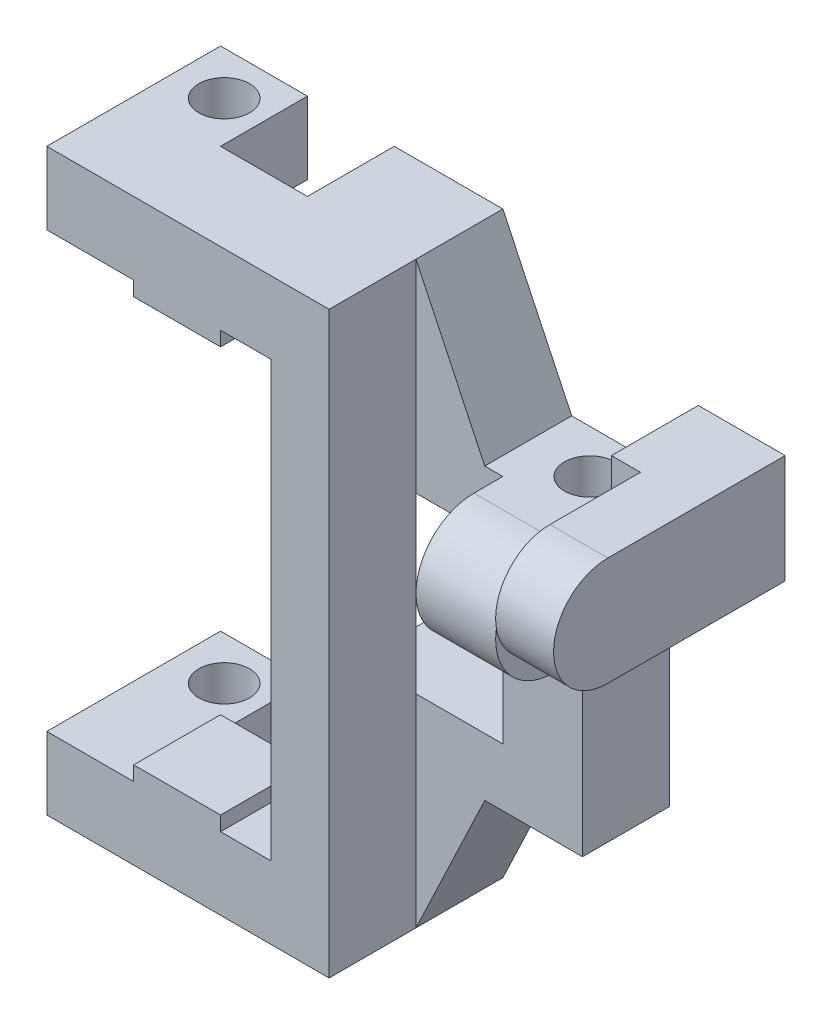
from build123d import *

# Parameters (mm, degrees)
BOSS_EXTRUDE1_DEPTH  = 6
SKETCH2_R            = 1.75
CUT_EXTRUDE1_DEPTH   = 41
SKETCH3_R            = 1.5
BOSS_EXTRUDE7_DEPTH  = 5.5
SKETCH4_W            = 4
SKETCH4_H            = 12
BOSS_EXTRUDE8_DEPTH  = 6
SKETCH7_W            = 6
SKETCH7_H            = 6
CUT_EXTRUDE2_DEPTH   = 40
BOSS_EXTRUDE9_DEPTH  = 6
BOSS_EXTRUDE10_DEPTH = 10
CUT_EXTRUDE3_REACH   = 41
SKETCH12_W           = 6
SKETCH12_H           = 6
BOSS_EXTRUDE11_DEPTH = 1
SKETCH13_W           = 6
SKETCH13_H           = 6
BOSS_EXTRUDE12_DEPTH = 1


with BuildPart() as part:
    # Sketch1 → Boss-Extrude1 (new body)
    with BuildSketch(Plane.XY):
        Polygon((6, 4), (-4, 4), (-4, -5), (-19.5, -5), (-19.5, -10), (0, -10), (4.75, 0), (11.5, 0), (11.5, 20), (4.75, 20), (0, 30), (-19.5, 30), (-19.5, 25), (-4, 25), (-4, 16), (6, 16), align=None)
    extrude(amount=BOSS_EXTRUDE1_DEPTH)

    # Sketch2 → Cut-Extrude1 (cut, through all)
    with BuildSketch(Plane.XZ.offset(10)):
        with Locations((9, 3)):
            Circle(SKETCH2_R)
        with Locations((-16.25, 3)):
            Circle(SKETCH2_R)
    extrude(amount=-CUT_EXTRUDE1_DEPTH, mode=Mode.SUBTRACT)

    # Sketch3 → Boss-Extrude7 (add)
    with BuildSketch(Plane(origin=(11.5, 0, 0), x_dir=(0, 0, -1), z_dir=(1, 0, 0))):
        with BuildLine():
            Line((-8, 12), (-6, 12))
            Line((-6, 12), (-6, 20))
            Line((-6, 20), (-8, 20))
            ThreePointArc((-8, 20), (-12, 16), (-8, 12))
        make_face()
        with Locations((-8, 16)):
            Circle(SKETCH3_R, mode=Mode.SUBTRACT)
    extrude(amount=-BOSS_EXTRUDE7_DEPTH)

    # Sketch4 → Boss-Extrude8 (add)
    with BuildSketch(Plane.XY.offset(6)):
        with Locations((-2, 10)):
            Rectangle(SKETCH4_W, SKETCH4_H)
        Polygon((-4, 16), (-4, 25), (-19.5, 25), (-19.5, 30), (0, 30), (0, 24), (0, 16), align=None)
        Polygon((-19.5, -5), (-19.5, -10), (0, -10), (0, 4), (-4, 4), (-4, -5), align=None)
    extrude(amount=BOSS_EXTRUDE8_DEPTH)

    # Sketch7 → Cut-Extrude2 (cut)
    with BuildSketch(Plane.XZ.offset(10)):
        with Locations((-10.5, 3)):
            Rectangle(SKETCH7_W, SKETCH7_H)
    extrude(amount=-CUT_EXTRUDE2_DEPTH, mode=Mode.SUBTRACT)

    # Sketch9 → Boss-Extrude9 (add)
    with BuildSketch(Plane(origin=(0, 0, 0), x_dir=(-1, 0, 0), z_dir=(0, 0, -1))):
        Polygon((-17.5, 17.5), (-11.5, 12), (-11.5, 20), (-13.5, 20), (-13.5, 25), (-19.5, 25), (-19.5, 20), (-19.5, 17.5), align=None)
    extrude(amount=-BOSS_EXTRUDE9_DEPTH)

    # Sketch10 → Boss-Extrude10 (add)
    with BuildSketch(Plane.XY.offset(6)):
        Polygon((19.5, 25), (15.5, 25), (15.5, 17.5), (17, 17.5), (17.5, 17.5), (19.5, 17.5), align=None)
    extrude(amount=BOSS_EXTRUDE10_DEPTH)

    # Sketch11 → Cut-Extrude3 (cut, up to next)
    with BuildSketch(Plane(origin=(19.5, 0, 0), x_dir=(0, 0, -1), z_dir=(1, 0, 0)), mode=Mode.PRIVATE) as cut_extrude3_sk1:
        with BuildLine():
            Line((-12.25, 25), (-16, 25))
            Line((-16, 25), (-16, 21.25))
            ThreePointArc((-16, 21.25), (-14.901650429, 23.901650429), (-12.25, 25))
        make_face()
    cut_extrude3_tool1 = extrude(cut_extrude3_sk1.sketch, amount=-CUT_EXTRUDE3_REACH, mode=Mode.PRIVATE) & part.part
    add(cut_extrude3_tool1.solids().sort_by_distance((19.5, 24.16237, 15.16237))[0], mode=Mode.SUBTRACT)
    # Sketch11 → Cut-Extrude3 (cut, up to next)
    with BuildSketch(Plane(origin=(19.5, 0, 0), x_dir=(0, 0, -1), z_dir=(1, 0, 0)), mode=Mode.PRIVATE) as cut_extrude3_sk2:
        with BuildLine():
            ThreePointArc((-12.25, 17.5), (-14.901650429, 18.598349571), (-16, 21.25))
            Line((-16, 21.25), (-16, 17.5))
            Line((-16, 17.5), (-12.25, 17.5))
        make_face()
    cut_extrude3_tool2 = extrude(cut_extrude3_sk2.sketch, amount=-CUT_EXTRUDE3_REACH, mode=Mode.PRIVATE) & part.part
    add(cut_extrude3_tool2.solids().sort_by_distance((19.5, 18.33763, 15.16237))[0], mode=Mode.SUBTRACT)

    # Sketch12 → Boss-Extrude11 (add)
    with BuildSketch(Plane.XZ.offset(-25)):
        with Locations((-10.5, 9)):
            Rectangle(SKETCH12_W, SKETCH12_H)
    extrude(amount=BOSS_EXTRUDE11_DEPTH)

    # Sketch13 → Boss-Extrude12 (add)
    with BuildSketch(Plane(origin=(0, -5, 0), x_dir=(1, 0, 0), z_dir=(0, 1, 0))):
        with Locations((-10.5, -9)):
            Rectangle(SKETCH13_W, SKETCH13_H)
    extrude(amount=BOSS_EXTRUDE12_DEPTH)


solid = part.part
